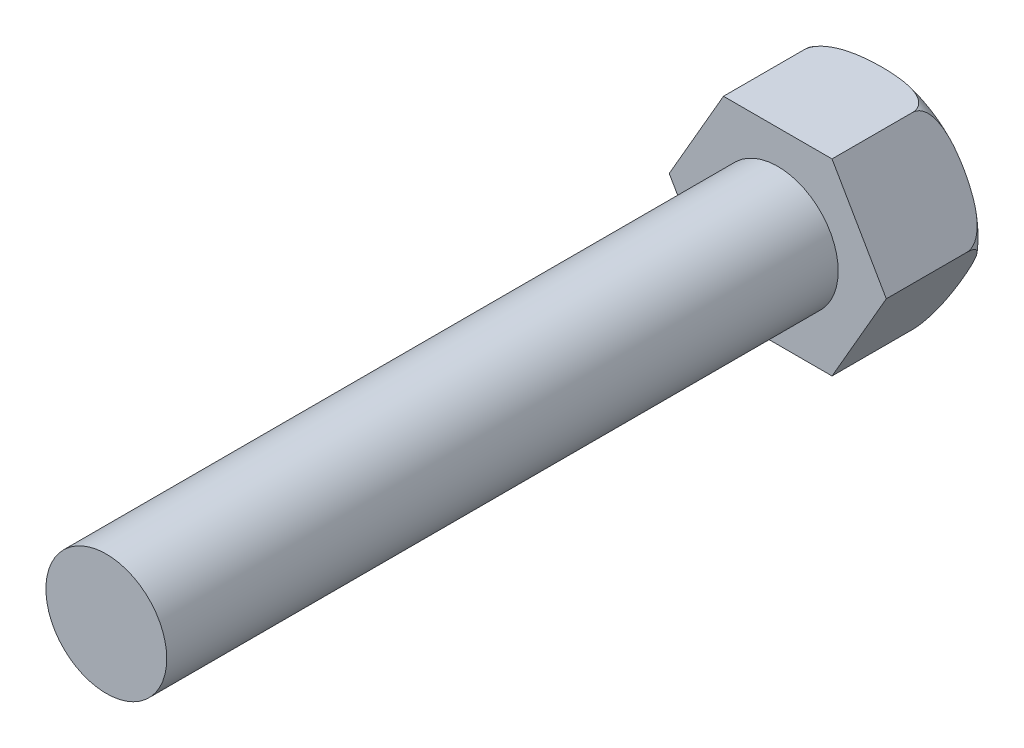
from build123d import *

# Parameters (mm, degrees)
BOSS_EXTRUDE1_DEPTH = 4
SKETCH2_R           = 2.25
BOSS_EXTRUDE2_DEPTH = 25


with BuildPart() as part:
    # Sketch1 → Boss-Extrude1 (new body)
    with BuildSketch(Plane.XY):
        Polygon((-4.041451884, 0), (-2.020725942, -3.5), (2.020725942, -3.5), (4.041451884, 0), (2.020725942, 3.5), (-2.020725942, 3.5), align=None)
    extrude(amount=BOSS_EXTRUDE1_DEPTH)

    # Sketch2 → Boss-Extrude2 (add)
    with BuildSketch(Plane.XY.offset(4)):
        Circle(SKETCH2_R)
    extrude(amount=BOSS_EXTRUDE2_DEPTH)

    # Sketch3 → Cut-Revolve1 (revolve, cut)
    with BuildSketch(Plane(origin=(0, 0, 0), x_dir=(1, 0, 0), z_dir=(0, 1, 0))):
        with BuildLine():
            Line((3.041451884, 0), (4.041451884, 0))
            Line((4.041451884, 0), (4.041451884, -1))
            ThreePointArc((4.041451884, -1), (3.748558666, -0.292893219), (3.041451884, 0))
        make_face()
    revolve(axis=Axis((0, 0, 29), (0, 0, -1)), mode=Mode.SUBTRACT)


solid = part.part
